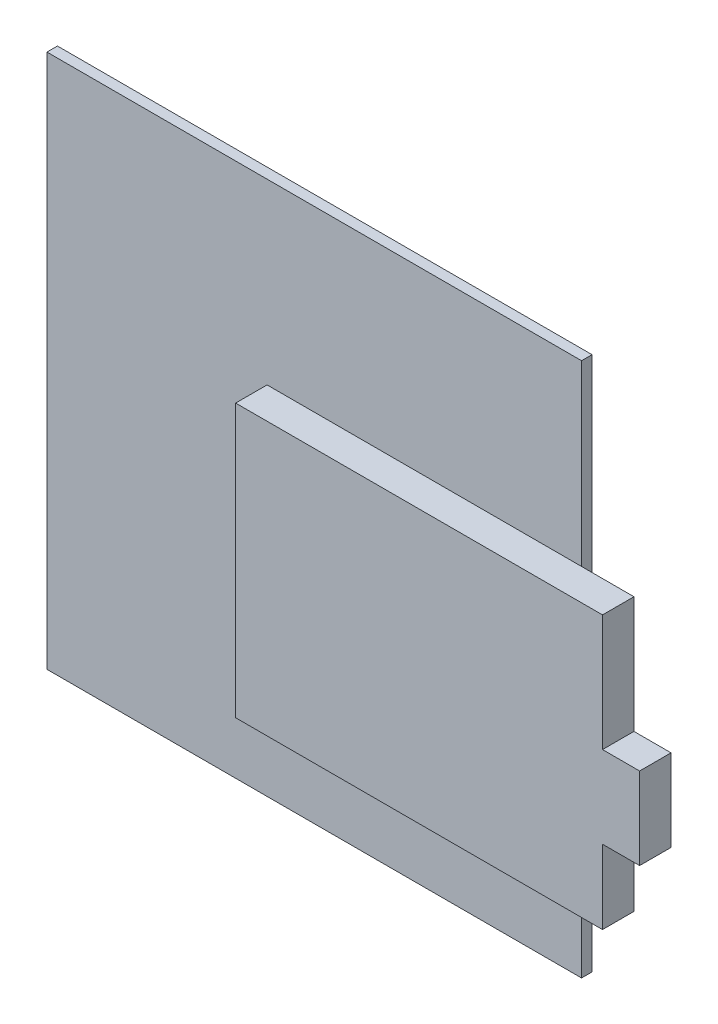
from build123d import *

# Parameters (mm, degrees)
CROQUIS1_W              = 51
CROQUIS1_H              = 52
SALIENTE_EXTRUIR1_DEPTH = 1
CROQUIS2_W              = 30
CROQUIS2_H              = 26
CROQUIS2_W_2            = 3.538114814
CROQUIS2_H_2            = 7.817941565
CROQUIS2_W_3            = 2.595962414
SALIENTE_EXTRUIR2_DEPTH = 3
CROQUIS3_W              = 51
CROQUIS3_H              = 1
CORTAR_EXTRUIR2_DEPTH   = 3


with BuildPart() as part:
    # Croquis1 → Saliente-Extruir1 (new body)
    with BuildSketch(Plane.XY):
        with Locations((25.5, -26)):
            Rectangle(CROQUIS1_W, CROQUIS1_H)
    extrude(amount=SALIENTE_EXTRUIR1_DEPTH)

    # Croquis2 → Saliente-Extruir2 (add)
    with BuildSketch(Plane.XY.offset(1)):
        with Locations((36, -31)):
            Rectangle(CROQUIS2_W, CROQUIS2_H)
        with Locations((57.769057407, -33.036147408)):
            Rectangle(CROQUIS2_W_2, CROQUIS2_H_2)
        with Locations((54.702018793, -33.036147408)):
            Rectangle(CROQUIS2_W_3, CROQUIS2_H_2)
        Polygon((56, -18), (51, -18), (51, -44), (56, -44), (56, -36.945118191), (53.404037586, -36.945118191), (53.404037586, -29.127176626), (56, -29.127176626), align=None)
    extrude(amount=SALIENTE_EXTRUIR2_DEPTH)

    # Croquis3 → Cortar-Extruir2 (cut)
    with BuildSketch(Plane.XY.offset(1)):
        with Locations((25.5, -0.5)):
            Rectangle(CROQUIS3_W, CROQUIS3_H)
    extrude(amount=-CORTAR_EXTRUIR2_DEPTH, mode=Mode.SUBTRACT)


solid = part.part
